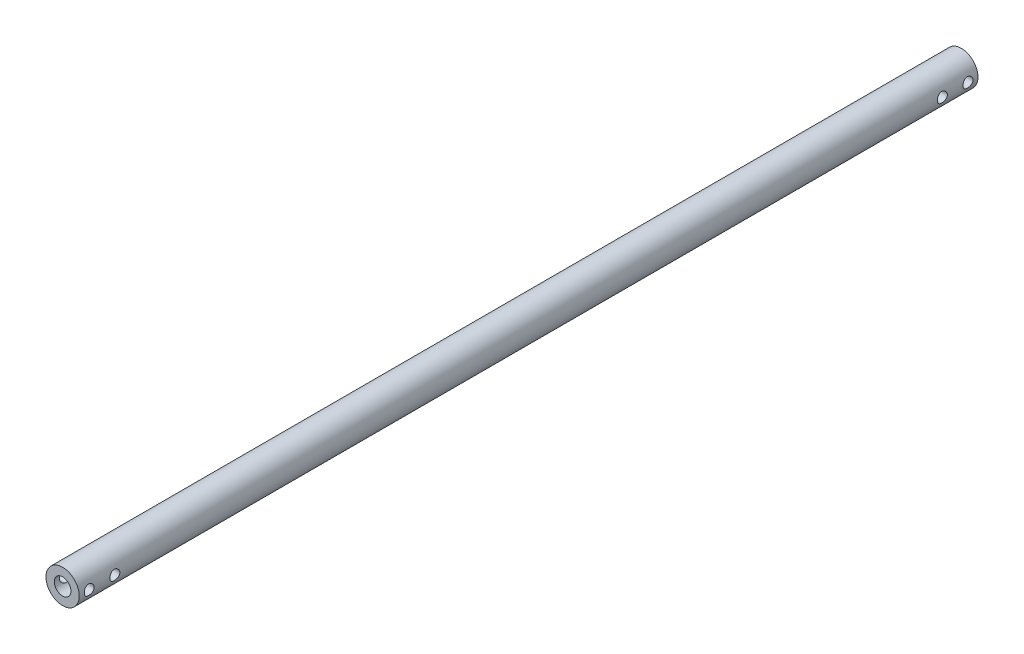
from build123d import *

# Parameters (mm, degrees)
SKETCH2_R           = 6.35
BOSS_EXTRUDE1_DEPTH = 342.9
SKETCH3_R           = 1.905
CUT_EXTRUDE5_DEPTH  = 177.8
SKETCH4_R           = 3.175
CUT_EXTRUDE6_DEPTH  = 343.9000001


with BuildPart() as part:
    # Sketch2 → Boss-Extrude1 (new body)
    with BuildSketch(Plane.XY):
        Circle(SKETCH2_R)
    extrude(amount=BOSS_EXTRUDE1_DEPTH)

    # Sketch3 → Cut-Extrude5 (cut, symmetric)
    with BuildSketch(Plane(origin=(0, 0, 0), x_dir=(0, 0, -1), z_dir=(1, 0, 0))):
        with Locations((-339.09, 0)):
            Circle(SKETCH3_R)
        with Locations((-329.311, 0)):
            Circle(SKETCH3_R)
        with Locations((-13.589, 0)):
            Circle(SKETCH3_R)
        with Locations((-3.81, 0)):
            Circle(SKETCH3_R)
    extrude(amount=CUT_EXTRUDE5_DEPTH, both=True, mode=Mode.SUBTRACT)

    # Sketch4 → Cut-Extrude6 (cut, through all)
    with BuildSketch(Plane(origin=(0, 0, 0), x_dir=(-1, 0, 0), z_dir=(0, 0, -1))):
        Circle(SKETCH4_R)
    extrude(amount=-CUT_EXTRUDE6_DEPTH, mode=Mode.SUBTRACT)


solid = part.part
